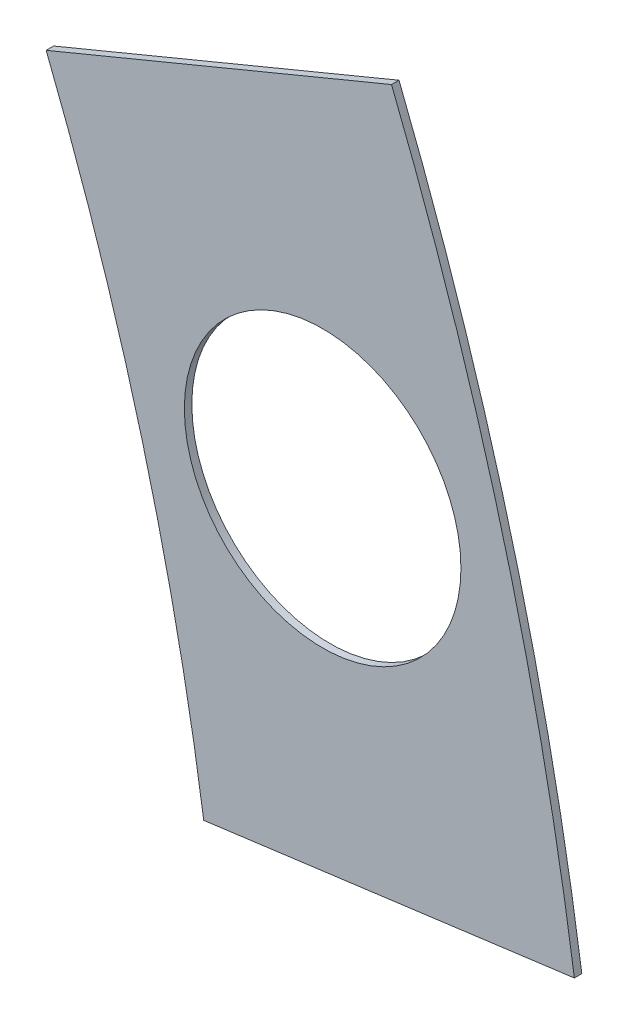
from build123d import *

# Parameters (mm, degrees)
BOSS_EXTRUDE1_DEPTH = 0.254
SKETCH2_R           = 4.699
CUT_EXTRUDE1_DEPTH  = 1.254
SKETCH3_W           = 2.54
SKETCH3_H           = 0.635
CUT_EXTRUDE2_DEPTH  = 1.254
SKETCH5_OUTSIDE_W   = 121.447
SKETCH5_OUTSIDE_H   = 109.618
CUT_EXTRUDE5_DEPTH  = 1.254


with BuildPart() as part:
    # Sketch1 → Boss-Extrude1 (new body)
    with BuildSketch(Plane.XY):
        with BuildLine():
            Line((67.21146711, 76.191723231), (8.696654013, 17.676910134))
            Line((8.696654013, 17.676910134), (7.228954972, 14.133571205))
            ThreePointArc((7.228954972, 14.133571205), (14.666587579, 6.075099489), (15.105587123, -4.88230096))
            Line((15.105587123, -4.88230096), (18.648926052, -6.35))
            Line((18.648926052, -6.35), (101.401368334, -6.35))
            ThreePointArc((101.401368334, -6.35), (93.866160503, 38.880636728), (67.21146711, 76.191723231))
        make_face()
        with BuildLine():
            Line((88.672924278, 6.35), (27.86051193, 6.35))
            ThreePointArc((27.86051193, 6.35), (26.399857642, 10.93517908), (24.190484974, 15.210228852))
            Line((24.190484974, 15.210228852), (67.191354125, 58.211098004))
            ThreePointArc((67.191354125, 58.211098004), (82.13289044, 34.020557137), (88.672924278, 6.35))
        make_face(mode=Mode.SUBTRACT)
    extrude(amount=BOSS_EXTRUDE1_DEPTH)

    # Sketch2 → Cut-Extrude1 (cut, through all)
    with BuildSketch(Plane.XY.offset(0.254)):
        with Locations((22.225, 0)):
            Circle(SKETCH2_R)
        with Locations((36.195, 0)):
            Circle(SKETCH2_R)
        with Locations((61.722, 0)):
            Circle(SKETCH2_R)
        with Locations((75.692, 0)):
            Circle(SKETCH2_R)
        with Locations((95.25, 0)):
            Circle(SKETCH2_R)
        with Locations((15.715448212, 15.715448212)):
            Circle(SKETCH2_R)
        with Locations((25.593729945, 25.593729945)):
            Circle(SKETCH2_R)
        with Locations((43.644044748, 43.644044748)):
            Circle(SKETCH2_R)
        with Locations((53.522326482, 53.522326482)):
            Circle(SKETCH2_R)
        with Locations((92.004434954, 24.652514046)):
            Circle(SKETCH2_R)
        with Locations((82.48891971, 47.625)):
            Circle(SKETCH2_R)
        with Locations((67.351920908, 67.351920908)):
            Circle(SKETCH2_R)
    extrude(amount=-CUT_EXTRUDE1_DEPTH, mode=Mode.SUBTRACT)

    # Sketch3 → Cut-Extrude2 (cut, through all)
    with BuildSketch(Plane.XY.offset(0.254)):
        Polygon((15.266435406, 24.246691527), (17.06248663, 26.042742751), (17.511499436, 25.593729945), (15.715448212, 23.797678721), align=None)
        Polygon((44.991083167, 53.971339288), (43.195031942, 52.175288063), (43.644044748, 51.726275257), (45.440095973, 53.522326482), align=None)
        with Locations((29.21, -6.0325)):
            Rectangle(SKETCH3_W, SKETCH3_H)
        with Locations((68.707, -6.0325)):
            Rectangle(SKETCH3_W, SKETCH3_H)
        Polygon((29.230733674, 38.210989795), (31.026784898, 40.007041019), (31.475797704, 39.558028213), (29.67974648, 37.761976989), align=None)
        Polygon((56.845021246, 65.825277367), (55.048970022, 64.029226143), (55.497982828, 63.580213337), (57.294034052, 65.376264561), align=None)
        with Locations((48.9585, -6.0325)):
            Rectangle(SKETCH3_W, SKETCH3_H)
        with Locations((85.471, -6.0325)):
            Rectangle(SKETCH3_W, SKETCH3_H)
        Polygon((99.935462164, 14.437711971), (100.266998693, 11.919442024), (101.526133667, 12.085210288), (101.194597138, 14.603480236), align=None)
        Polygon((93.765504959, 37.464305742), (94.938831965, 37.950313702), (93.966816047, 40.296967714), (92.793489041, 39.810959755), align=None)
        Polygon((79.327792988, 62.471156422), (80.874047017, 60.456038938), (81.88160576, 61.229165953), (80.33535173, 63.244283437), align=None)
        Polygon((13.593916116, 7.005422516), (14.565932035, 4.658768503), (15.739259041, 5.144776462), (14.767243123, 7.491430475), align=None)
    extrude(amount=-CUT_EXTRUDE2_DEPTH, mode=Mode.SUBTRACT)

    # Sketch5 outside → Cut-Extrude5 (cut, through all)
    with BuildSketch(Plane.XY.offset(0.254)):
        with Locations((54.4145, 34.921)):
            Rectangle(SKETCH5_OUTSIDE_W, SKETCH5_OUTSIDE_H)
        with BuildLine():
            Line((81.437068577, 32.35770019), (95.518252433, 38.190317518))
            ThreePointArc((95.518252433, 38.190317518), (99.36478975, 26.62471517), (101.816391891, 14.685341068))
            Line((101.816391891, 14.685341068), (86.705420292, 12.695943916))
            ThreePointArc((86.705420292, 12.695943916), (84.644080158, 22.680312922), (81.437068577, 32.35770019))
        make_face(mode=Mode.SUBTRACT)
    extrude(amount=-CUT_EXTRUDE5_DEPTH, mode=Mode.SUBTRACT)


solid = part.part
